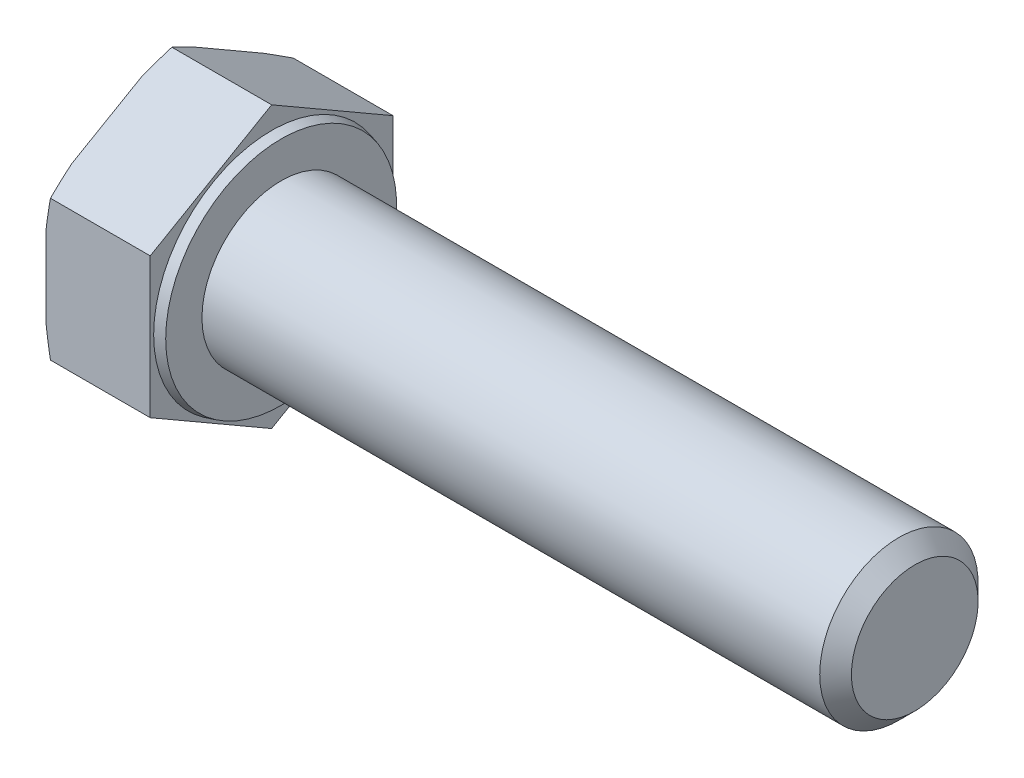
from build123d import *

# Parameters (mm, degrees)
SKETCH_2_OUTSIDE_W  = 30.382
SKETCH_2_OUTSIDE_H  = 30.382
CUT_EXTRUDE_1_DEPTH = 49.811857166
CHAMFER_1_SIZE      = 1


with BuildPart() as part:
    # Эскиз1 → Повернуть1 (revolve)
    with BuildSketch(Plane.XY, mode=Mode.PRIVATE) as revolve_1_sk:
        Polygon((-6.58, 0), (-6.58, 8.85), (0, 8.85), (0, 7.448974596), (0.6, 7.288205081), (0.6, 5), (40.6, 5), (40.6, 0), align=None)
    revolve(revolve_1_sk.sketch.rotate(Axis((-1000, 0, 0), (1, 0, 0)), 90), axis=Axis((-1000, 0, 0), (1, 0, 0)))

    # Эскиз2 outside → Вырез-Вытянуть1 (cut, through all)
    with BuildSketch(Plane.ZY.offset(6.58)):
        Rectangle(SKETCH_2_OUTSIDE_W, SKETCH_2_OUTSIDE_H)
        Polygon((0, -8.85), (7.664324823, -4.425), (7.664324823, 4.425), (0, 8.85), (-7.664324823, 4.425), (-7.664324823, -4.425), align=None, mode=Mode.SUBTRACT)
    extrude(amount=-CUT_EXTRUDE_1_DEPTH, mode=Mode.SUBTRACT)

    # Эскиз4 → Вырез-Повернуть1 (revolve, cut)
    with BuildSketch(Plane.XY):
        Polygon((-6.58, 8.075), (-6.297923068, 8.85), (-6.58, 8.85), align=None)
    revolve(axis=Axis((-1000, 0, 0), (1, 0, 0)), mode=Mode.SUBTRACT)

    # Фаска1
    chamfer_1_edges = [part.edges().sort_by_distance(p)[0] for p in [
        (40.6, 0, -5),
    ]]
    chamfer(chamfer_1_edges, length=CHAMFER_1_SIZE)


solid = part.part
